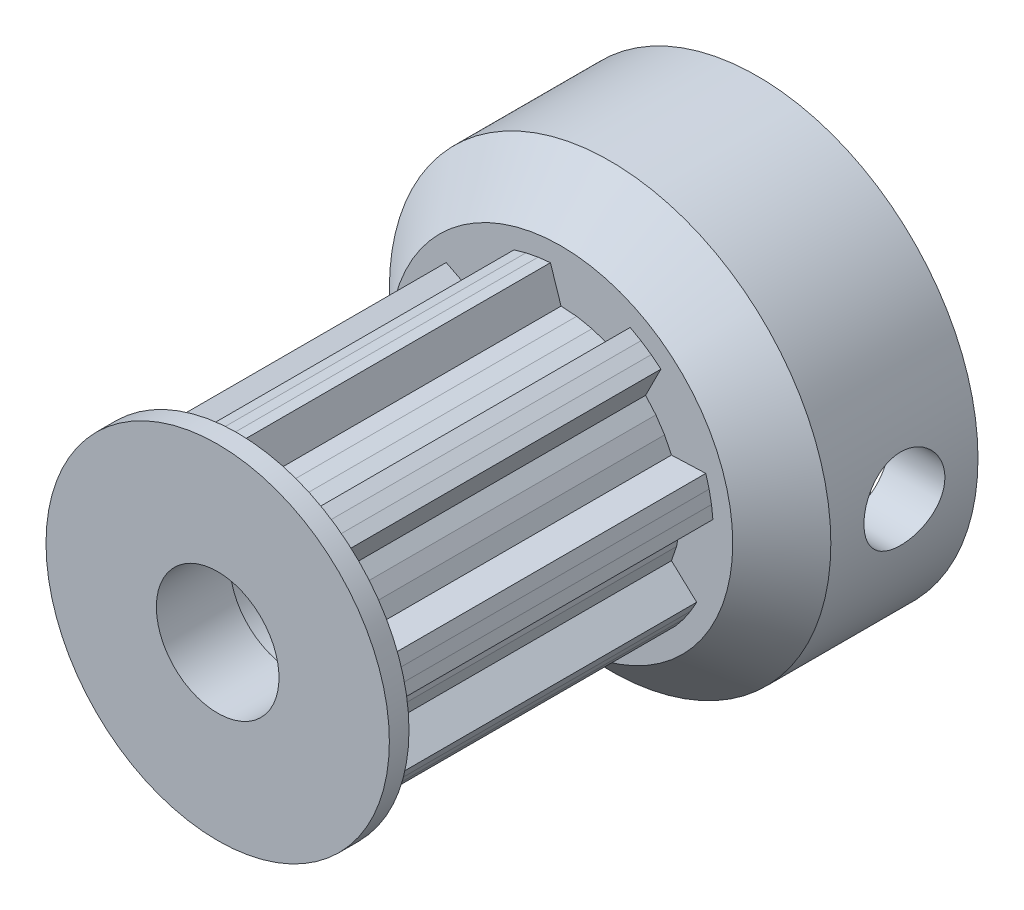
from build123d import *

# Parameters (mm, degrees)
SKETCH2_R           = 2.625
BOSS_EXTRUDE1_DEPTH = 14
SKETCH3_R           = 9
BOSS_EXTRUDE2_DEPTH = 8
SKETCH4_R           = 2.5
CUT_EXTRUDE1_DEPTH  = 23
CHAMFER1_SIZE       = 2
CUT_EXTRUDE2_DEPTH  = 2.7
CUT_EXTRUDE3_REACH  = 20
SKETCH7_R           = 1.65
CHAMFER2_SIZE       = 0.5
CHAMFER3_SIZE       = 0.5


with BuildPart() as part:
    # Sketch2 → Boss-Extrude1 (new body)
    with BuildSketch(Plane.XY):
        Polygon((4.873707771, 0), (4.832012177, -0.636146486), (4.707640171, -1.261407971), (4.502718925, -1.865087032), (5.52904892, -2.817190886), (5.281517029, -3.257688046), (4.998967171, -3.676585913), (4.683272839, -4.071106911), (3.44623208, -3.44623208), (2.966924906, -3.866571903), (2.436853886, -4.2207551), (1.865087032, -4.502718925), (1.917572975, -5.901682854), (1.431063056, -6.038129807), (0.935064673, -6.134541988), (0.432866603, -6.190280914), (0, -4.873707771), (-0.636146486, -4.832012177), (-1.261407971, -4.707640171), (-1.865087032, -4.502718925), (-2.817190886, -5.52904892), (-3.257688046, -5.281517029), (-3.676585913, -4.998967171), (-4.071106911, -4.683272839), (-3.44623208, -3.44623208), (-3.866571903, -2.966924906), (-4.2207551, -2.436853886), (-4.502718925, -1.865087032), (-5.901682854, -1.917572975), (-6.038129807, -1.431063056), (-6.134541988, -0.935064673), (-6.190280914, -0.432866603), (-4.873707771, 0), (-4.832012177, 0.636146486), (-4.707640171, 1.261407971), (-4.502718925, 1.865087032), (-5.52904892, 2.817190886), (-5.281517029, 3.257688046), (-4.998967171, 3.676585913), (-4.683272839, 4.071106911), (-3.44623208, 3.44623208), (-2.966924906, 3.866571903), (-2.436853886, 4.2207551), (-1.865087032, 4.502718925), (-1.917572975, 5.901682854), (-1.431063056, 6.038129807), (-0.935064673, 6.134541988), (-0.432866603, 6.190280914), (0, 4.873707771), (0.636146486, 4.832012177), (1.261407971, 4.707640171), (1.865087032, 4.502718925), (2.817190886, 5.52904892), (3.257688046, 5.281517029), (3.676585913, 4.998967171), (4.071106911, 4.683272839), (3.44623208, 3.44623208), (3.866571903, 2.966924906), (4.2207551, 2.436853886), (4.502718925, 1.865087032), (5.901682854, 1.917572975), (6.038129807, 1.431063056), (6.134541988, 0.935064673), (6.190280914, 0.432866603), align=None)
        Circle(SKETCH2_R, mode=Mode.SUBTRACT)
    extrude(amount=BOSS_EXTRUDE1_DEPTH)

    # Sketch3 → Boss-Extrude2 (add)
    with BuildSketch(Plane(origin=(0, 0, 0), x_dir=(-1, 0, 0), z_dir=(0, 0, -1))):
        Circle(SKETCH3_R)
    extrude(amount=BOSS_EXTRUDE2_DEPTH)

    # Sketch4 → Cut-Extrude1 (cut, through all)
    with BuildSketch(Plane(origin=(0, 0, -8), x_dir=(-1, 0, 0), z_dir=(0, 0, -1))):
        Circle(SKETCH4_R)
    extrude(amount=-CUT_EXTRUDE1_DEPTH, mode=Mode.SUBTRACT)

    # Sketch5 → Revolve1 (revolve)
    with BuildSketch(Plane(origin=(0, 0, 0), x_dir=(1, 0, 0), z_dir=(0, 1, 0))):
        Polygon((2.5, -14), (7, -14), (7, -13.2), (2.5, -11), align=None)
    revolve(axis=Axis((0, 0, 0), (0, 0, 1)))

    # Chamfer1
    chamfer1_edges = [part.edges().sort_by_distance(p)[0] for p in [
        (9, 0, 0),
    ]]
    chamfer(chamfer1_edges, length=CHAMFER1_SIZE)

    # Sketch6 → Cut-Extrude2 (cut)
    with BuildSketch(Plane(origin=(4, 0, 0), x_dir=(0, 0, -1), z_dir=(1, 0, 0))):
        Polygon((8, 2.9), (8, -2.9), (3.325684219, -2.9), (1.651368439, 0), (3.325684219, 2.9), align=None)
    extrude(amount=CUT_EXTRUDE2_DEPTH, mode=Mode.SUBTRACT)

    # Cut-Extrude3: up to this face of the body
    cut_extrude3_end = part.part.faces().sort_by_distance((2.5, 0, -4))[0]
    # Sketch7 → Cut-Extrude3 (cut, up to the picked face)
    with BuildSketch(Plane(origin=(9, 0, 0), x_dir=(0, 0, -1), z_dir=(1, 0, 0)), mode=Mode.PRIVATE) as cut_extrude3_sk1:
        with Locations((5, 0)):
            Circle(SKETCH7_R)
    cut_extrude3_tool1 = split(extrude(cut_extrude3_sk1.sketch, amount=-CUT_EXTRUDE3_REACH, mode=Mode.PRIVATE), bisect_by=cut_extrude3_end, keep=Keep.BOTH, mode=Mode.PRIVATE)
    add(cut_extrude3_tool1.solids().sort_by_distance((9, 0, -5))[0], mode=Mode.SUBTRACT)

    # Chamfer2
    chamfer2_edges = [part.edges().sort_by_distance(p)[0] for p in [
        (5.35, 2.9, -8),
        (5.35, -2.9, -8),
    ]]
    chamfer(chamfer2_edges, length=CHAMFER2_SIZE)

    # Chamfer3
    chamfer3_edges = [part.edges().sort_by_distance(p)[0] for p in [
        (2.5, 0, -8),
    ]]
    chamfer(chamfer3_edges, length=CHAMFER3_SIZE)


solid = part.part
